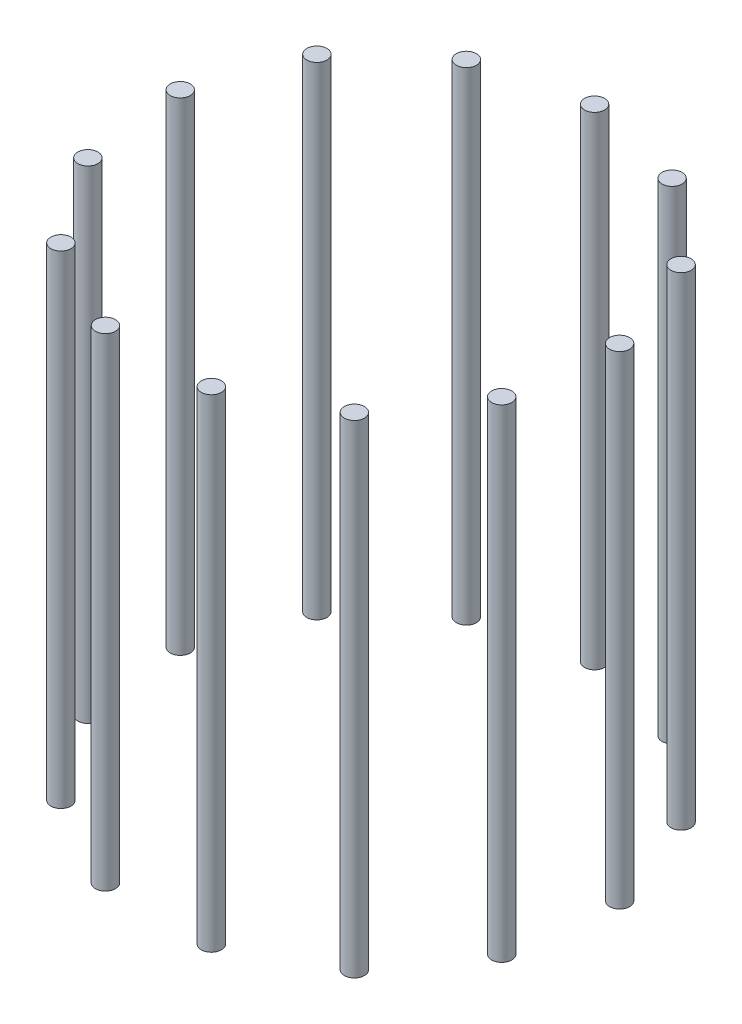
from build123d import *

# Parameters (mm, degrees)
SKETCH1_R       = 0.25
PINOVI_DEPTH    = 12
PINOVI_2_DEPTH  = 12
PINOVI_3_DEPTH  = 12
PINOVI_4_DEPTH  = 12
PINOVI_5_DEPTH  = 12
PINOVI_6_DEPTH  = 12
PINOVI_7_DEPTH  = 12
PINOVI_8_DEPTH  = 12
PINOVI_9_DEPTH  = 12
PINOVI_10_DEPTH = 12
PINOVI_11_DEPTH = 12
PINOVI_12_DEPTH = 12
PINOVI_13_DEPTH = 12


with BuildPart() as part:
    # Sketch1 → pinovi (new body)
    with BuildSketch(Plane(origin=(0, 0, 0), x_dir=(1, 0, 0), z_dir=(0, 1, 0))):
        with Locations((0, 5.5)):
            Circle(SKETCH1_R)
    extrude(amount=-PINOVI_DEPTH)


with BuildPart() as body_2:
    # Sketch1 → pinovi 2 (new body)
    with BuildSketch(Plane(origin=(0, 0, 0), x_dir=(1, 0, 0), z_dir=(0, 1, 0))):
        with Locations((2.555977446, 4.870008141)):
            Circle(SKETCH1_R)
    extrude(amount=-PINOVI_2_DEPTH)


with BuildPart() as body_3:
    # Sketch1 → pinovi 3 (new body)
    with BuildSketch(Plane(origin=(0, 0, 0), x_dir=(1, 0, 0), z_dir=(0, 1, 0))):
        with Locations((4.526411262, 3.124356107)):
            Circle(SKETCH1_R)
    extrude(amount=-PINOVI_3_DEPTH)


with BuildPart() as body_4:
    # Sketch1 → pinovi 4 (new body)
    with BuildSketch(Plane(origin=(0, 0, 0), x_dir=(1, 0, 0), z_dir=(0, 1, 0))):
        with Locations((5.459898808, 0.662951741)):
            Circle(SKETCH1_R)
    extrude(amount=-PINOVI_4_DEPTH)


with BuildPart() as body_5:
    # Sketch1 → pinovi 5 (new body)
    with BuildSketch(Plane(origin=(0, 0, 0), x_dir=(1, 0, 0), z_dir=(0, 1, 0))):
        with Locations((5.142589335, -1.950326879)):
            Circle(SKETCH1_R)
    extrude(amount=-PINOVI_5_DEPTH)


with BuildPart() as body_6:
    # Sketch1 → pinovi 6 (new body)
    with BuildSketch(Plane(origin=(0, 0, 0), x_dir=(1, 0, 0), z_dir=(0, 1, 0))):
        with Locations((3.64717462, -4.116809115)):
            Circle(SKETCH1_R)
    extrude(amount=-PINOVI_6_DEPTH)


with BuildPart() as body_7:
    # Sketch1 → pinovi 7 (new body)
    with BuildSketch(Plane(origin=(0, 0, 0), x_dir=(1, 0, 0), z_dir=(0, 1, 0))):
        with Locations((1.316236154, -5.340179996)):
            Circle(SKETCH1_R)
    extrude(amount=-PINOVI_7_DEPTH)


with BuildPart() as body_8:
    # Sketch1 → pinovi 8 (new body)
    with BuildSketch(Plane(origin=(0, 0, 0), x_dir=(1, 0, 0), z_dir=(0, 1, 0))):
        with Locations((-1.316236154, -5.340179996)):
            Circle(SKETCH1_R)
    extrude(amount=-PINOVI_8_DEPTH)


with BuildPart() as body_9:
    # Sketch1 → pinovi 9 (new body)
    with BuildSketch(Plane(origin=(0, 0, 0), x_dir=(1, 0, 0), z_dir=(0, 1, 0))):
        with Locations((-3.64717462, -4.116809115)):
            Circle(SKETCH1_R)
    extrude(amount=-PINOVI_9_DEPTH)


with BuildPart() as body_10:
    # Sketch1 → pinovi 10 (new body)
    with BuildSketch(Plane(origin=(0, 0, 0), x_dir=(1, 0, 0), z_dir=(0, 1, 0))):
        with Locations((-5.142589335, -1.950326879)):
            Circle(SKETCH1_R)
    extrude(amount=-PINOVI_10_DEPTH)


with BuildPart() as body_11:
    # Sketch1 → pinovi 11 (new body)
    with BuildSketch(Plane(origin=(0, 0, 0), x_dir=(1, 0, 0), z_dir=(0, 1, 0))):
        with Locations((-5.459898808, 0.662951741)):
            Circle(SKETCH1_R)
    extrude(amount=-PINOVI_11_DEPTH)


with BuildPart() as body_12:
    # Sketch1 → pinovi 12 (new body)
    with BuildSketch(Plane(origin=(0, 0, 0), x_dir=(1, 0, 0), z_dir=(0, 1, 0))):
        with Locations((-4.526411262, 3.124356107)):
            Circle(SKETCH1_R)
    extrude(amount=-PINOVI_12_DEPTH)


with BuildPart() as body_13:
    # Sketch1 → pinovi 13 (new body)
    with BuildSketch(Plane(origin=(0, 0, 0), x_dir=(1, 0, 0), z_dir=(0, 1, 0))):
        with Locations((-2.555977446, 4.870008141)):
            Circle(SKETCH1_R)
    extrude(amount=-PINOVI_13_DEPTH)


solid = Compound([part.part, body_2.part, body_3.part, body_4.part, body_5.part, body_6.part, body_7.part, body_8.part, body_9.part, body_10.part, body_11.part, body_12.part, body_13.part])
